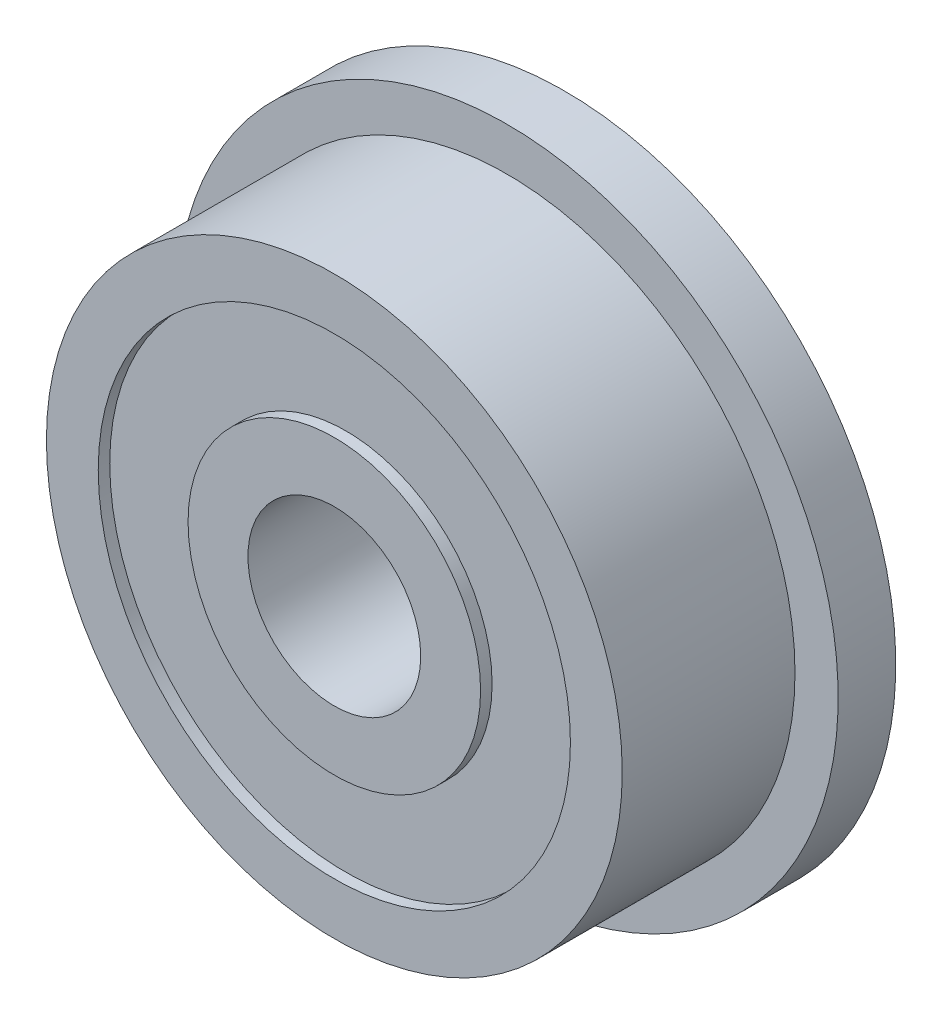
from build123d import *

# Parameters (mm, degrees)
SKETCH_1_R          = 5
EXTRUDE_1_DEPTH     = 2
SKETCH_4_R          = 5.75
EXTRUDE_2_DEPTH     = 1
SKETCH_2_R          = 1.5
CUT_EXTRUDE_1_DEPTH = 5
SKETCH_3_R          = 4.1
SKETCH_3_R_2        = 2.54
CUT_EXTRUDE_2_DEPTH = 0.2


with BuildPart() as part:
    # 草圖1 → 填料-伸長1 (new body, symmetric)
    with BuildSketch(Plane.XY):
        Circle(SKETCH_1_R)
    extrude(amount=EXTRUDE_1_DEPTH, both=True)

    # 草圖4 → 填料-伸長2 (add)
    with BuildSketch(Plane(origin=(0, 0, -2), x_dir=(-1, 0, 0), z_dir=(0, 0, -1))):
        Circle(SKETCH_4_R)
    extrude(amount=-EXTRUDE_2_DEPTH)

    # 草圖2 → 除料-伸長1 (cut, through all)
    with BuildSketch(Plane.XY.offset(2)):
        Circle(SKETCH_2_R)
    extrude(amount=-CUT_EXTRUDE_1_DEPTH, mode=Mode.SUBTRACT)

    # 草圖3 → 除料-伸長2 (cut)
    with BuildSketch(Plane.XY.offset(2)):
        Circle(SKETCH_3_R)
        Circle(SKETCH_3_R_2, mode=Mode.SUBTRACT)
    cut_extrude_2 = extrude(amount=-CUT_EXTRUDE_2_DEPTH, mode=Mode.SUBTRACT)

    # 鏡射1: 除料-伸長2 across plane
    add(cut_extrude_2.mirror(Plane.XY), mode=Mode.SUBTRACT)


solid = part.part
